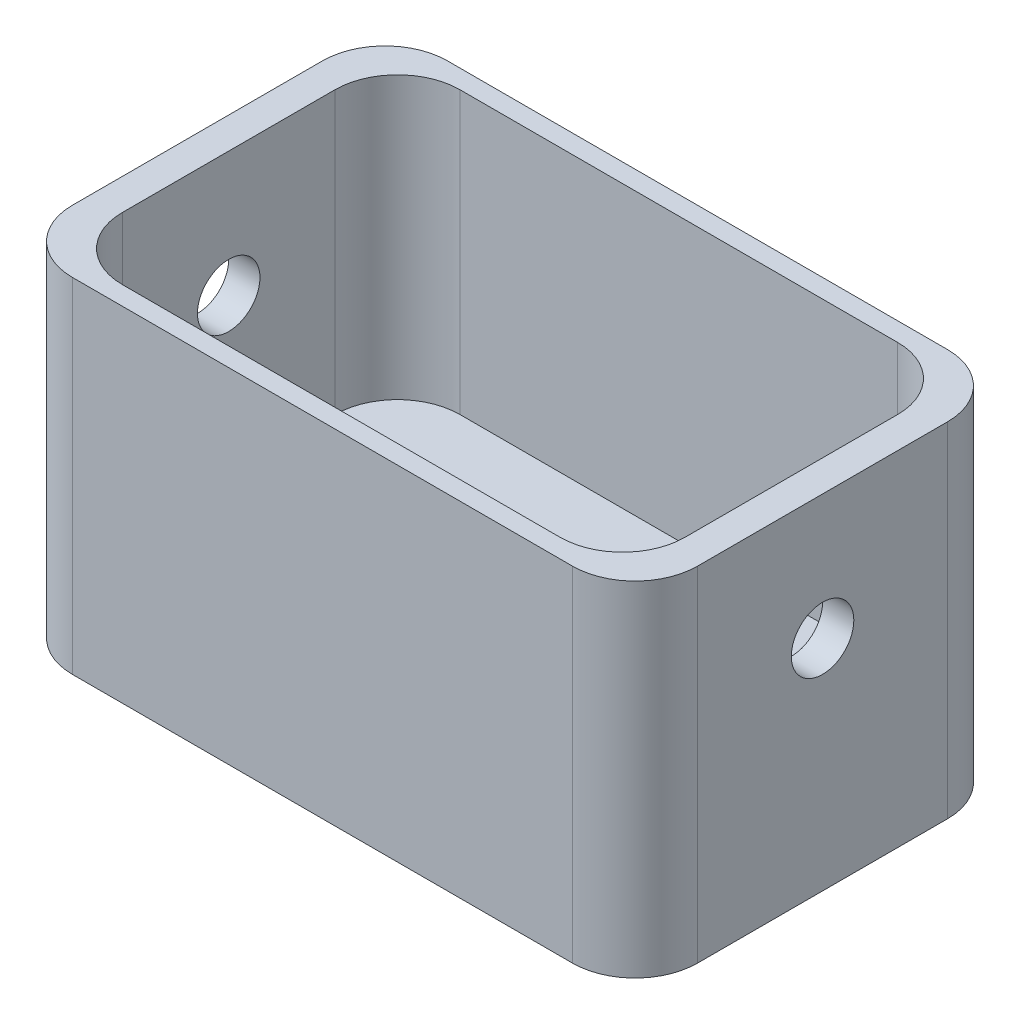
from build123d import *

# Parameters (mm, degrees)
ESBO_O3_W                = 100
ESBO_O3_H                = 60
RESSALTO_EXTRUS_O1_DEPTH = 55
ESBO_O4_W                = 90
ESBO_O4_H                = 54
CORTE_EXTRUS_O1_DEPTH    = 45
ESBO_O5_R                = 5
CORTE_EXTRUS_O2_DEPTH    = 100
FILETE1_R                = 10


with BuildPart() as part:
    # Esboço3 → Ressalto-extrusão1 (new body)
    with BuildSketch(Plane(origin=(0, 0, 0), x_dir=(1, 0, 0), z_dir=(0, 1, 0))):
        Rectangle(ESBO_O3_W, ESBO_O3_H)
    extrude(amount=RESSALTO_EXTRUS_O1_DEPTH)

    # Esboço4 → Corte-extrusão1 (cut)
    with BuildSketch(Plane(origin=(0, 55, 0), x_dir=(1, 0, 0), z_dir=(0, 1, 0))):
        Rectangle(ESBO_O4_W, ESBO_O4_H)
    extrude(amount=-CORTE_EXTRUS_O1_DEPTH, mode=Mode.SUBTRACT)

    # Esboço5 → Corte-extrusão2 (cut)
    with BuildSketch(Plane(origin=(50, 0, 0), x_dir=(0, 0, -1), z_dir=(1, 0, 0))):
        with Locations((0, 35)):
            Circle(ESBO_O5_R)
    extrude(amount=-CORTE_EXTRUS_O2_DEPTH, mode=Mode.SUBTRACT)

    # Filete1
    filete1_edges = [part.edges().sort_by_distance(p)[0] for p in [
        (-45, 32.5, 27),
        (-45, 32.5, -27),
        (45, 32.5, -27),
        (45, 32.5, 27),
        (-50, 27.5, -30),
        (50, 27.5, -30),
        (50, 27.5, 30),
        (-50, 27.5, 30),
    ]]
    fillet(filete1_edges, radius=FILETE1_R)


solid = part.part
